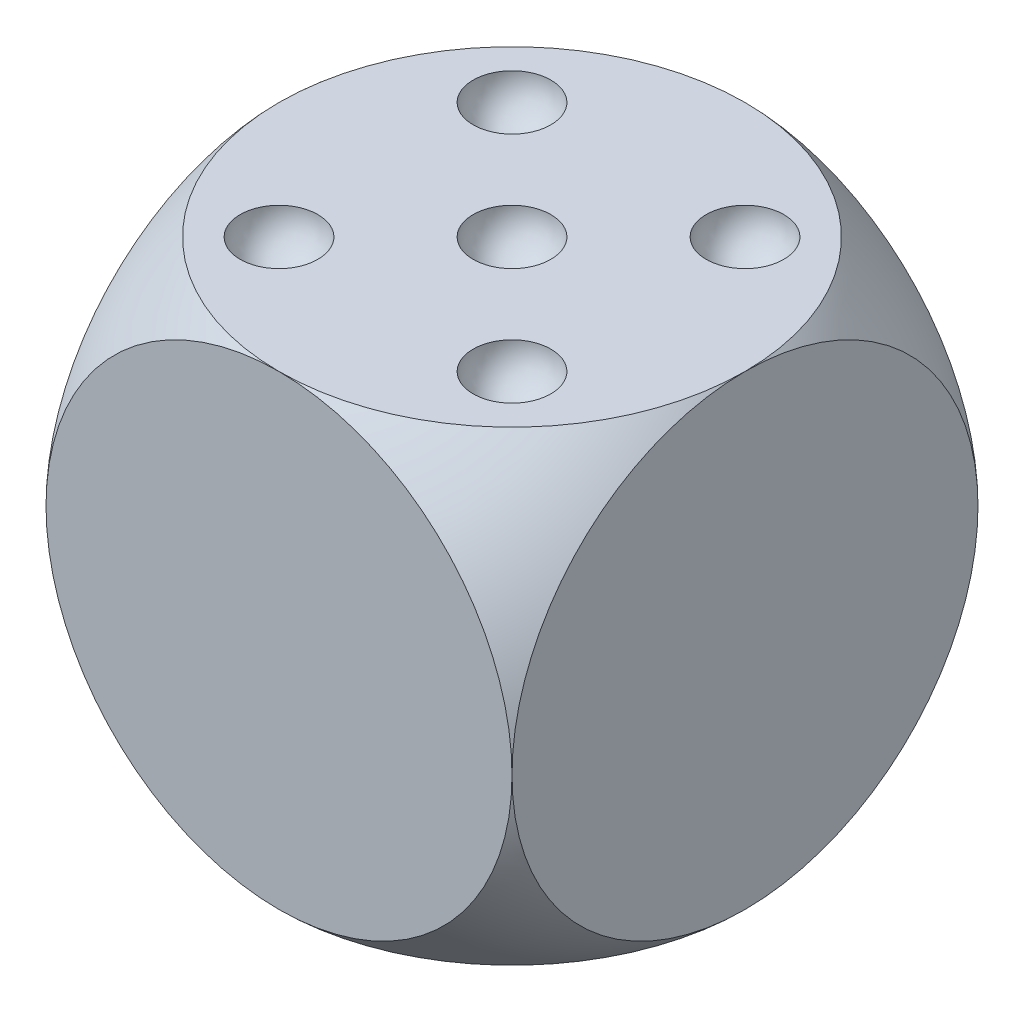
from build123d import *

# Parameters (mm, degrees)
SKETCH1_W            = 60
SKETCH1_H            = 60
BOSS_EXTRUDE1_DEPTH  = 30
LPATTERN2_COUNT      = 3
LPATTERN2_PITCH      = 15
LPATTERN2_COUNT_DIR2 = 3
LPATTERN2_PITCH_DIR2 = 15


with BuildPart() as part:
    # Sketch1 → Boss-Extrude1 (new body, symmetric)
    with BuildSketch(Plane.XY):
        Rectangle(SKETCH1_W, SKETCH1_H)
    extrude(amount=BOSS_EXTRUDE1_DEPTH, both=True)

    # Sketch3 → Cut-Revolve1 (revolve, cut)
    with BuildSketch(Plane(origin=(0, 0, 0), x_dir=(1, 0, 0), z_dir=(0, 1, 0))):
        with BuildLine():
            Line((0, -50), (62, -50))
            Line((62, -50), (62, 50))
            Line((62, 50), (0, 50))
            Line((0, 50), (0, 42.426406871))
            ThreePointArc((0, 42.426406871), (42.426406871, 0), (0, -42.426406871))
            Line((0, -42.426406871), (0, -50))
        make_face()
    revolve(axis=Axis((0, 0, -60.912631334), (0, 0, 1)), mode=Mode.SUBTRACT)

    # Sketch4 → Cut-Revolve2 (revolve, cut)
    with BuildSketch(Plane(origin=(0, 30, 0), x_dir=(1, 0, 0), z_dir=(0, 1, 0))):
        with BuildLine():
            Line((-15, -10), (-15, -20))
            ThreePointArc((-15, -20), (-10, -15), (-15, -10))
        make_face()
    cut_revolve2 = revolve(axis=Axis((-15, 30, 10), (0, 0, 1)), mode=Mode.SUBTRACT)

    # LPattern2: Cut-Revolve2 3 × 3, 4 skipped
    with Locations(*[(j * LPATTERN2_PITCH_DIR2, 0, -i * LPATTERN2_PITCH) for i in range(LPATTERN2_COUNT) for j in range(LPATTERN2_COUNT_DIR2) if (i, j) not in ((0, 0), (0, 1), (1, 0), (1, 2), (2, 1))]):
        add(cut_revolve2, mode=Mode.SUBTRACT)


solid = part.part
